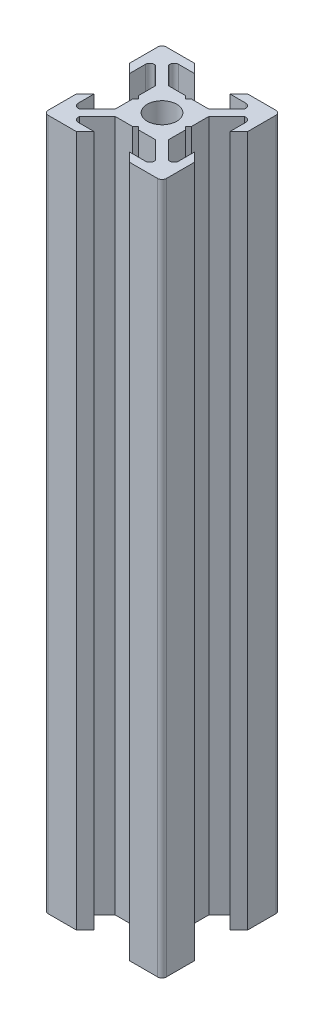
from build123d import *

# Parameters (mm, degrees)
ESQUISSE1_R      = 2.5
EXTRUSION1_DEPTH = 117
CONG_1_R         = 0.75


with BuildPart() as part:
    # Esquisse1 → Extrusion1 (new body)
    with BuildSketch(Plane(origin=(0, 0, 0), x_dir=(1, 0, 0), z_dir=(0, 1, 0))):
        Polygon((0, 4), (-0.5, 4.5), (-3.439339828, 4.5), (-6.439339828, 7.5), (-6.439339828, 8.5), (-3, 8.5), (-4.5, 10), (-10, 10), (-10, 4.5), (-8.5, 3), (-8.5, 6.439339828), (-7.5, 6.439339828), (-4.5, 3.439339828), (-4.5, 0.5), (-4, 0), (-4.5, -0.5), (-4.5, -3.439339828), (-7.5, -6.439339828), (-8.5, -6.439339828), (-8.5, -3), (-10, -4.5), (-10, -10), (-4.5, -10), (-3, -8.5), (-6.439339828, -8.5), (-6.439339828, -7.5), (-3.439339828, -4.5), (-0.5, -4.5), (0, -4), (0.5, -4.5), (3.439339828, -4.5), (6.439339828, -7.5), (6.439339828, -8.5), (3, -8.5), (4.5, -10), (10, -10), (10, -4.5), (8.5, -3), (8.5, -6.439339828), (7.5, -6.439339828), (4.5, -3.439339828), (4.5, -0.5), (4, 0), (4.5, 0.5), (4.5, 3.439339828), (7.5, 6.439339828), (8.5, 6.439339828), (8.5, 3), (10, 4.5), (10, 10), (4.5, 10), (3, 8.5), (6.439339828, 8.5), (6.439339828, 7.5), (3.439339828, 4.5), (0.5, 4.5), align=None)
        Circle(ESQUISSE1_R, mode=Mode.SUBTRACT)
    extrude(amount=EXTRUSION1_DEPTH)

    # Congé1
    cong_1_edges = [part.edges().sort_by_distance(p)[0] for p in [
        (6.439339828, 58.5, -8.5),
        (10, 58.5, -10),
        (8.5, 58.5, -6.439339828),
        (8.5, 58.5, 6.439339828),
        (10, 58.5, 10),
        (6.439339828, 58.5, 8.5),
        (-6.439339828, 58.5, 8.5),
        (-10, 58.5, 10),
        (-8.5, 58.5, 6.439339828),
        (-8.5, 58.5, -6.439339828),
        (-10, 58.5, -10),
        (-6.439339828, 58.5, -8.5),
    ]]
    fillet(cong_1_edges, radius=CONG_1_R)


solid = part.part
